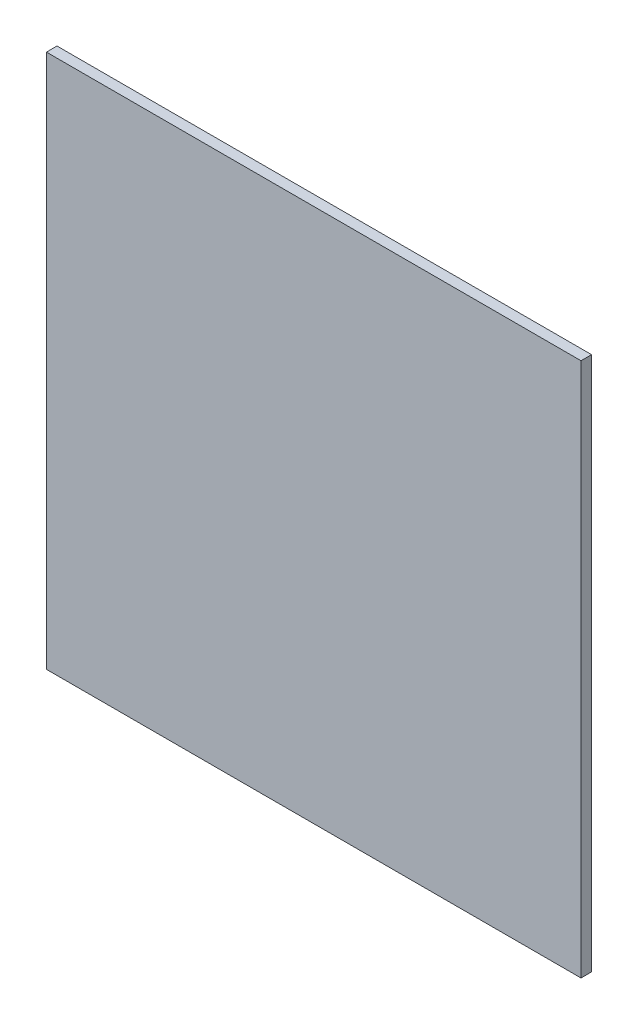
from build123d import *

# Parameters (mm, degrees)
SKETCH1_W           = 241.3
SKETCH1_H           = 241.3
BOSS_EXTRUDE1_DEPTH = 4.7625


with BuildPart() as part:
    # Sketch1 → Boss-Extrude1 (new body)
    with BuildSketch(Plane.XY):
        Rectangle(SKETCH1_W, SKETCH1_H)
    extrude(amount=BOSS_EXTRUDE1_DEPTH)


solid = part.part
